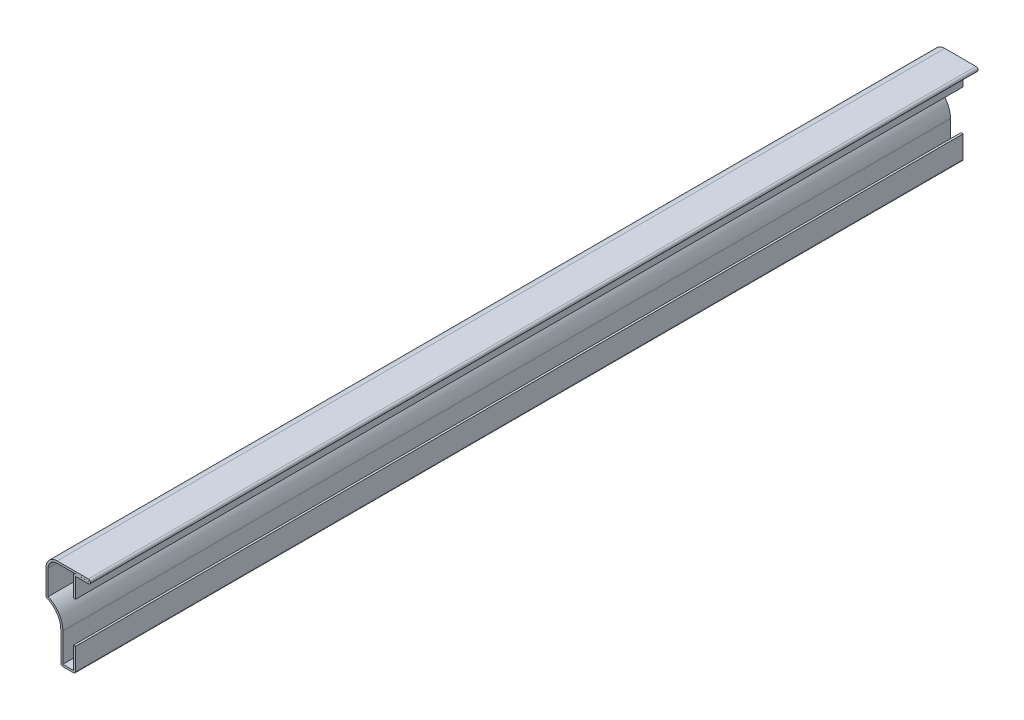
from build123d import *

# Parameters (mm, degrees)
EXTRUDE_THIN1_DEPTH = 381
FILLET1_R           = 0.889


with BuildPart() as part:
    # Sketch1 → Extrude-Thin1 (new body)
    with BuildSketch(Plane.XY):
        with BuildLine():
            Line((0, 27.78125), (0, 36.2966))
            Line((0, 36.2966), (5.4483, 36.2966))
            ThreePointArc((5.4483, 36.2966), (6.35, 37.1983), (5.4483, 38.1))
            Line((5.4483, 38.1), (-7.9375, 38.1))
            ThreePointArc((-7.9375, 38.1), (-11.305096045, 36.705096045), (-12.7, 33.3375))
            Line((-12.7, 33.3375), (-12.7, 22.225))
            ThreePointArc((-12.7, 22.225), (-8.097870067, 18.744005193), (-6.35, 13.244743879))
            Line((-6.35, 13.244743879), (-6.35, 0))
            Line((-6.35, 0), (0, 0))
            Line((0, 0), (0, 10.31875))
            Line((0, 10.31875), (-0.889, 10.31875))
            Line((-0.889, 10.31875), (-0.889, 0.889))
            Line((-0.889, 0.889), (-5.461, 0.889))
            Line((-5.461, 0.889), (-5.461, 13.244743879))
            ThreePointArc((-5.461, 13.244743879), (-7.192434365, 18.994913442), (-11.811, 22.833033612))
            Line((-11.811, 22.833033612), (-11.811, 33.3375))
            ThreePointArc((-11.811, 33.3375), (-10.676478117, 36.076478117), (-7.9375, 37.211))
            Line((-7.9375, 37.211), (5.4483, 37.211))
            ThreePointArc((5.4483, 37.211), (5.461, 37.1983), (5.4483, 37.1856))
            Line((5.4483, 37.1856), (-0.889, 37.1856))
            Line((-0.889, 37.1856), (-0.889, 27.78125))
            Line((-0.889, 27.78125), (0, 27.78125))
        make_face()
    extrude(amount=-EXTRUDE_THIN1_DEPTH)

    # Fillet1
    fillet1_edges = [part.edges().sort_by_distance(p)[0] for p in [
        (0, 0, -190.5),
        (-6.35, 0, -190.5),
        (-12.7, 22.225, -190.5),
        (-0.889, 37.1856, -190.5),
    ]]
    fillet(fillet1_edges, radius=FILLET1_R)


solid = part.part
